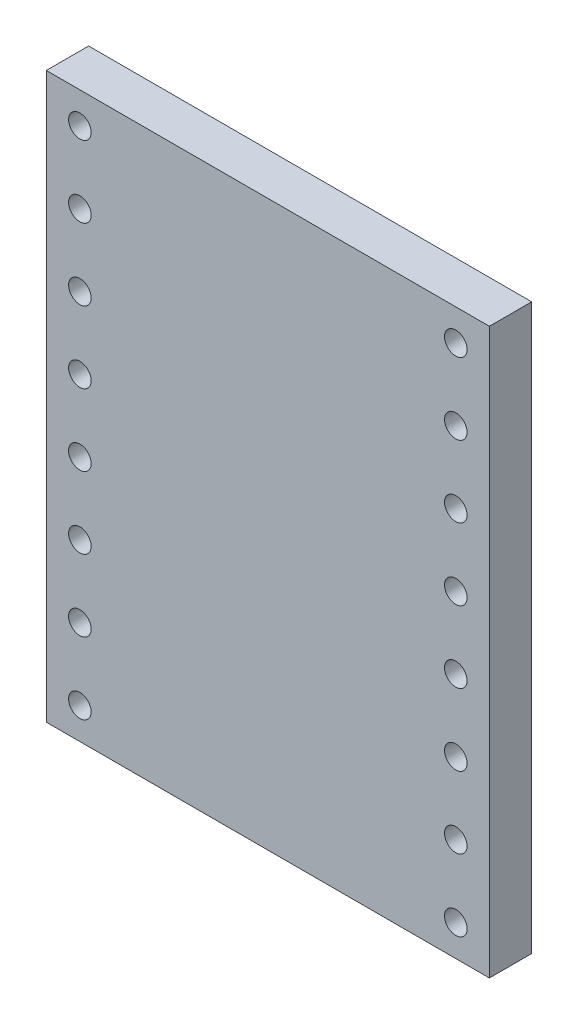
from build123d import *

# Parameters (mm, degrees)
SCHIZZO1_W                   = 15.7
SCHIZZO1_H                   = 20
ESTRUSIONE_ESTRUSIONE1_DEPTH = 1.5
SCHIZZO2_R                   = 0.4
TAGLIO_ESTRUSIONE1_DEPTH     = 1.5


with BuildPart() as part:
    # Schizzo1 → Estrusione-Estrusione1 (new body)
    with BuildSketch(Plane.XY):
        Rectangle(SCHIZZO1_W, SCHIZZO1_H)
    extrude(amount=ESTRUSIONE_ESTRUSIONE1_DEPTH)

    # Schizzo2 → Taglio-Estrusione1 (cut)
    with BuildSketch(Plane.XY.offset(1.5)):
        with Locations((-6.66, 8.89)):
            Circle(SCHIZZO2_R)
        with Locations((-6.66, 6.35)):
            Circle(SCHIZZO2_R)
        with Locations((-6.66, 3.81)):
            Circle(SCHIZZO2_R)
        with Locations((-6.66, 1.27)):
            Circle(SCHIZZO2_R)
        with Locations((-6.66, -1.27)):
            Circle(SCHIZZO2_R)
        with Locations((-6.66, -3.81)):
            Circle(SCHIZZO2_R)
        with Locations((-6.66, -6.35)):
            Circle(SCHIZZO2_R)
        with Locations((-6.66, -8.89)):
            Circle(SCHIZZO2_R)
        with Locations((6.66, -8.89)):
            Circle(SCHIZZO2_R)
        with Locations((6.66, -6.35)):
            Circle(SCHIZZO2_R)
        with Locations((6.66, -3.81)):
            Circle(SCHIZZO2_R)
        with Locations((6.66, -1.27)):
            Circle(SCHIZZO2_R)
        with Locations((6.66, 1.27)):
            Circle(SCHIZZO2_R)
        with Locations((6.66, 3.81)):
            Circle(SCHIZZO2_R)
        with Locations((6.66, 6.35)):
            Circle(SCHIZZO2_R)
        with Locations((6.66, 8.89)):
            Circle(SCHIZZO2_R)
    extrude(amount=-TAGLIO_ESTRUSIONE1_DEPTH, mode=Mode.SUBTRACT)


solid = part.part
